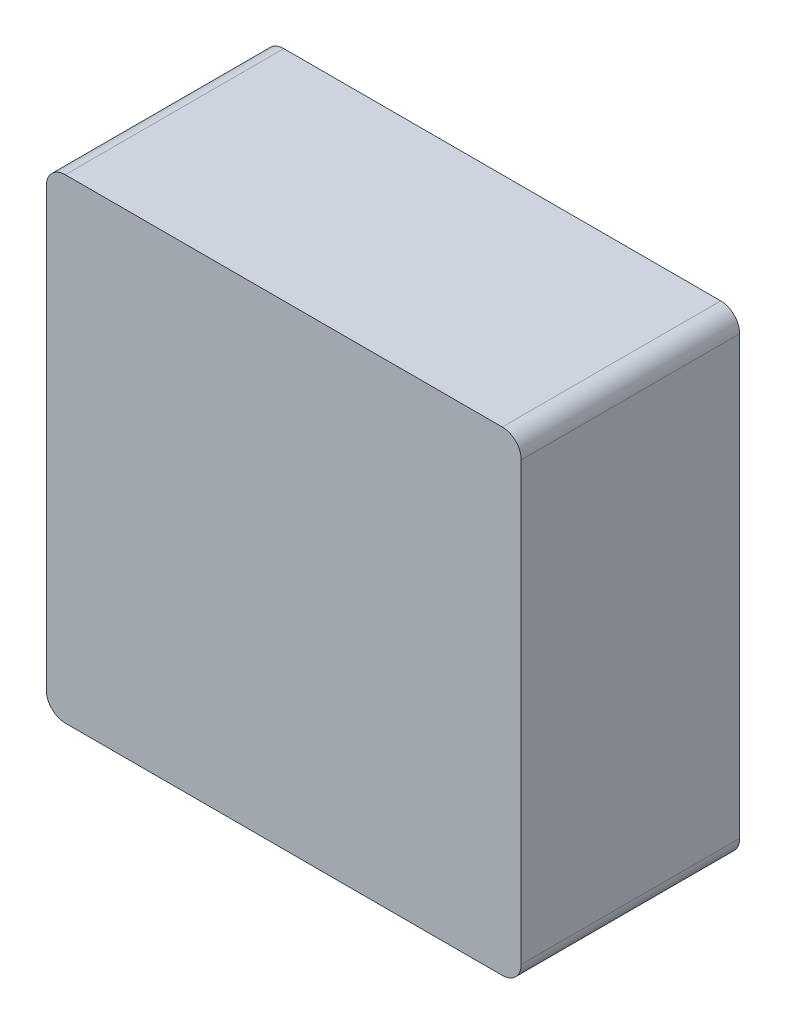
from build123d import *

# Parameters (mm, degrees)
SZKIC1_W                           = 30
SZKIC1_H                           = 3
DODANIE_WYCI_GNI_CIE1_DEPTH        = 23
DODANIE_WYCI_GNI_CIE1_DEPTH_BACK   = 2
SZKIC1_W_2                         = 3
SZKIC1_H_2                         = 30
DODANIE_WYCI_GNI_CIE1_2_DEPTH      = 23
DODANIE_WYCI_GNI_CIE1_2_DEPTH_BACK = 2
DODANIE_WYCI_GNI_CIE1_3_DEPTH      = 23
DODANIE_WYCI_GNI_CIE1_3_DEPTH_BACK = 2
DODANIE_WYCI_GNI_CIE1_4_DEPTH      = 23
DODANIE_WYCI_GNI_CIE1_4_DEPTH_BACK = 2
SZKIC2_W                           = 50
SZKIC2_H                           = 50
DODANIE_WYCI_GNI_CIE2_DEPTH        = 23
SZKIC3_W                           = 11.8
SZKIC3_H                           = 4.5
SZKIC3_R                           = 1
SZKIC3_W_2                         = 10.1
SZKIC3_W_3                         = 18.1
DODANIE_WYCI_GNI_CIE3_DEPTH        = 23
ZAOKR_GLENIE1_R                    = 2
WYTNIJ_WYCI_GNI_CIE1_REACH         = 52
SZKIC4_R                           = 6.5
SZKIC5_W                           = 46
SZKIC5_H                           = 46
DODANIE_WYCI_GNI_CIE4_DEPTH        = 2
DODANIE_WYCI_GNI_CIE5_START        = -10
SZKIC6_R                           = 1.05
SZKIC6_R_2                         = 1
DODANIE_WYCI_GNI_CIE5_DEPTH        = 11


with BuildPart() as part:
    # Szkic1 → Dodanie-wyciągnięcie1 (new body, two sides)
    with BuildSketch(Plane.XY) as dodanie_wyci_gni_cie1_sk:
        with Locations((0, 21.5)):
            Rectangle(SZKIC1_W, SZKIC1_H)
    extrude(amount=DODANIE_WYCI_GNI_CIE1_DEPTH)
    extrude(dodanie_wyci_gni_cie1_sk.sketch, amount=-DODANIE_WYCI_GNI_CIE1_DEPTH_BACK)



with BuildPart() as body_2:
    # Szkic1 → Dodanie-wyci_gni_cie1 2 (new body, two sides)
    with BuildSketch(Plane.XY) as dodanie_wyci_gni_cie1_2_sk:
        with Locations((21.5, 0)):
            Rectangle(SZKIC1_W_2, SZKIC1_H_2)
    extrude(amount=DODANIE_WYCI_GNI_CIE1_2_DEPTH)
    extrude(dodanie_wyci_gni_cie1_2_sk.sketch, amount=-DODANIE_WYCI_GNI_CIE1_2_DEPTH_BACK)


with BuildPart() as body_3:
    # Szkic1 → Dodanie-wyci_gni_cie1 3 (new body, two sides)
    with BuildSketch(Plane.XY) as dodanie_wyci_gni_cie1_3_sk:
        with Locations((0, -21.5)):
            Rectangle(SZKIC1_W, SZKIC1_H)
    extrude(amount=DODANIE_WYCI_GNI_CIE1_3_DEPTH)
    extrude(dodanie_wyci_gni_cie1_3_sk.sketch, amount=-DODANIE_WYCI_GNI_CIE1_3_DEPTH_BACK)


with BuildPart() as body_4:
    # Szkic1 → Dodanie-wyci_gni_cie1 4 (new body, two sides)
    with BuildSketch(Plane.XY) as dodanie_wyci_gni_cie1_4_sk:
        with Locations((-21.5, 0)):
            Rectangle(SZKIC1_W_2, SZKIC1_H_2)
    extrude(amount=DODANIE_WYCI_GNI_CIE1_4_DEPTH)
    extrude(dodanie_wyci_gni_cie1_4_sk.sketch, amount=-DODANIE_WYCI_GNI_CIE1_4_DEPTH_BACK)


with BuildPart() as part_1:
    add(part.part)

    add(body_2.part)  # Dodanie-wyciągnięcie2 merges body 2

    add(body_3.part)  # Dodanie-wyciągnięcie2 merges body 3

    add(body_4.part)  # Dodanie-wyciągnięcie2 merges body 4
    # Szkic2 → Dodanie-wyciągnięcie2 (add)
    with BuildSketch(Plane.XY):
        Rectangle(SZKIC2_W, SZKIC2_H)
        with BuildLine():
            Line((-21, -23), (21, -23))
            ThreePointArc((21, -23), (22.414213562, -22.414213562), (23, -21))
            Line((23, -21), (23, 21))
            ThreePointArc((23, 21), (22.414213562, 22.414213562), (21, 23))
            Line((21, 23), (-21, 23))
            ThreePointArc((-21, 23), (-22.414213562, 22.414213562), (-23, 21))
            Line((-23, 21), (-23, -21))
            ThreePointArc((-23, -21), (-22.414213562, -22.414213562), (-21, -23))
        make_face(mode=Mode.SUBTRACT)
    extrude(amount=DODANIE_WYCI_GNI_CIE2_DEPTH)

    # Szkic3 → Dodanie-wyciągnięcie3 (add)
    with BuildSketch(Plane.XY.offset(23)):
        Polygon((-1.9, -17.3), (-1.9, -12.8), (-20, -12.8), (-20, -15), (-23, -15), (-23, -17.3), align=None)
        with Locations((4, -15.05)):
            Rectangle(SZKIC3_W, SZKIC3_H)
        with Locations((4, -15)):
            Circle(SZKIC3_R, mode=Mode.SUBTRACT)
        Polygon((20, -12.8), (9.9, -12.8), (9.9, -17.3), (23, -17.3), (23, -15), (20, -15), align=None)
        with Locations((14.95, 12.35)):
            Rectangle(SZKIC3_W_2, SZKIC3_H)
        with Locations((4, 12.35)):
            Rectangle(SZKIC3_W, SZKIC3_H)
        with Locations((4, 12.3)):
            Circle(SZKIC3_R, mode=Mode.SUBTRACT)
        with Locations((-10.95, 12.35)):
            Rectangle(SZKIC3_W_3, SZKIC3_H)
    extrude(amount=-DODANIE_WYCI_GNI_CIE3_DEPTH)

    # Zaokrąglenie1
    zaokr_glenie1_edges = [part_1.edges().sort_by_distance(p)[0] for p in [
        (-25, -25, 11.5),
        (-25, 25, 11.5),
        (25, 25, 11.5),
        (25, -25, 11.5),
    ]]
    fillet(zaokr_glenie1_edges, radius=ZAOKR_GLENIE1_R)

    # Szkic4 → Wytnij-wyciągnięcie1 (cut, up to next)
    with BuildSketch(Plane.ZY.offset(25), mode=Mode.PRIVATE) as wytnij_wyci_gni_cie1_sk1:
        with Locations((10, -1.35)):
            Circle(SZKIC4_R)
    wytnij_wyci_gni_cie1_tool1 = extrude(wytnij_wyci_gni_cie1_sk1.sketch, amount=-WYTNIJ_WYCI_GNI_CIE1_REACH, mode=Mode.PRIVATE) & part_1.part
    add(wytnij_wyci_gni_cie1_tool1.solids().sort_by_distance((-25, -1.35, 10))[0], mode=Mode.SUBTRACT)

    # Szkic5 → Dodanie-wyciągnięcie4 (add)
    with BuildSketch(Plane.XY.offset(23)):
        Rectangle(SZKIC5_W, SZKIC5_H)
    extrude(amount=-DODANIE_WYCI_GNI_CIE4_DEPTH)

    # Szkic6 → Dodanie-wyciągnięcie5 (add)
    with BuildSketch(Plane(origin=(0, 0, 0), x_dir=(-1, 0, 0), z_dir=(0, 0, -1)).offset(DODANIE_WYCI_GNI_CIE5_START)):
        with Locations((-4, 12.25)):
            Circle(SZKIC6_R)
        with Locations((-4, -15)):
            Circle(SZKIC6_R_2)
    extrude(amount=-DODANIE_WYCI_GNI_CIE5_DEPTH)


solid = part_1.part
